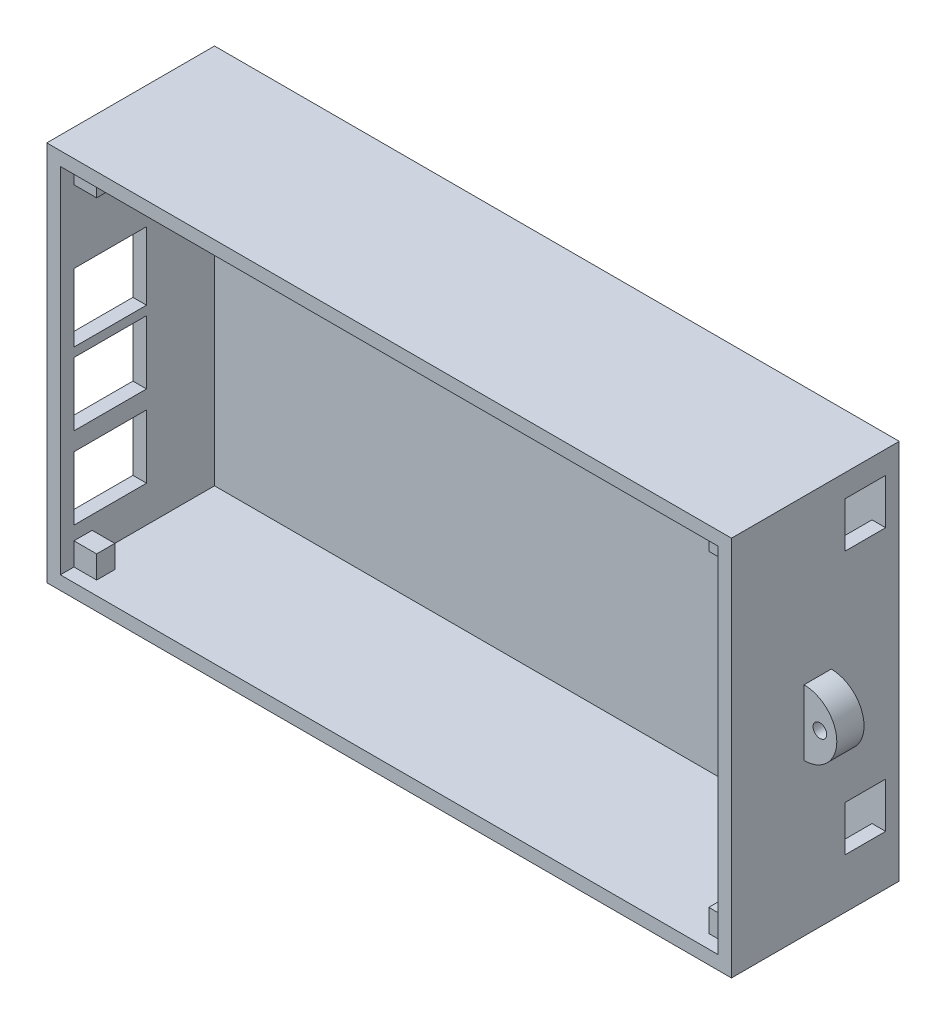
from build123d import *

# Parameters (mm, degrees)
SKETCH1_W                = 151
SKETCH1_H                = 84
BOSS_EXTRUDE1_DEPTH      = 37
SKETCH3_W                = 145
SKETCH3_H                = 78
CUT_EXTRUDE3_DEPTH       = 34
SKETCH8_W                = 19
SKETCH8_H                = 14
CUT_EXTRUDE4_DEPTH       = 3
SKETCH9_W                = 19
SKETCH9_H                = 14
CUT_EXTRUDE5_DEPTH       = 3
SKETCH11_W               = 9
SKETCH11_H               = 10
CUT_EXTRUDE6_DEPTH       = 3
SKETCH12_W               = 9
SKETCH12_H               = 10
CUT_EXTRUDE7_DEPTH       = 3
BOSS_EXTRUDE2_DEPTH      = 3
BOSS_EXTRUDE2_DEPTH_BACK = 3
SKETCH19_R               = 1.5
CUT_EXTRUDE8_DEPTH       = 6
SKETCH20_W               = 3
SKETCH20_H               = 14
BOSS_EXTRUDE3_DEPTH      = 3
SKETCH21_W               = 3
SKETCH21_H               = 14
BOSS_EXTRUDE4_DEPTH      = 3
SKETCH23_W               = 16
SKETCH23_H               = 15
CUT_EXTRUDE9_DEPTH       = 3
SKETCH28_W               = 4
SKETCH28_H               = 5
BOSS_EXTRUDE5_DEPTH      = 5
MIRROR2_COPY_1_SKETCH_W  = 4
MIRROR2_COPY_1_SKETCH_H  = 5
MIRROR2_COPY_1_DEPTH     = 5


with BuildPart() as part:
    # Sketch1 → Boss-Extrude1 (new body)
    with BuildSketch(Plane.XY):
        Rectangle(SKETCH1_W, SKETCH1_H)
    extrude(amount=BOSS_EXTRUDE1_DEPTH)

    # Sketch3 → Cut-Extrude3 (cut)
    with BuildSketch(Plane.XY.offset(37)):
        Rectangle(SKETCH3_W, SKETCH3_H)
    extrude(amount=-CUT_EXTRUDE3_DEPTH, mode=Mode.SUBTRACT)

    # Sketch8 → Cut-Extrude4 (cut)
    with BuildSketch(Plane.ZY.offset(75.5)):
        with Locations((27.5, -24)):
            Rectangle(SKETCH8_W, SKETCH8_H)
    extrude(amount=-CUT_EXTRUDE4_DEPTH, mode=Mode.SUBTRACT)

    # Sketch9 → Cut-Extrude5 (cut)
    with BuildSketch(Plane.ZY.offset(75.5)):
        with Locations((27.5, -6)):
            Rectangle(SKETCH9_W, SKETCH9_H)
    extrude(amount=-CUT_EXTRUDE5_DEPTH, mode=Mode.SUBTRACT)

    # Sketch11 → Cut-Extrude6 (cut)
    with BuildSketch(Plane(origin=(75.5, 0, 0), x_dir=(0, 0, -1), z_dir=(1, 0, 0))):
        with Locations((-7.5, 32)):
            Rectangle(SKETCH11_W, SKETCH11_H)
    extrude(amount=-CUT_EXTRUDE6_DEPTH, mode=Mode.SUBTRACT)

    # Sketch12 → Cut-Extrude7 (cut)
    with BuildSketch(Plane(origin=(75.5, 0, 0), x_dir=(0, 0, -1), z_dir=(1, 0, 0))):
        with Locations((-7.5, -26)):
            Rectangle(SKETCH12_W, SKETCH12_H)
    extrude(amount=-CUT_EXTRUDE7_DEPTH, mode=Mode.SUBTRACT)

    # Sketch16 → Boss-Extrude2 (add, two sides)
    with BuildSketch(Plane.XY.offset(18)) as boss_extrude2_sk:
        with BuildLine():
            Line((75.5, 6), (75.5, -8.461119278))
            ThreePointArc((75.5, -8.461119278), (82.730559639, -1.230559639), (75.5, 6))
        make_face()
    extrude(amount=BOSS_EXTRUDE2_DEPTH)
    extrude(boss_extrude2_sk.sketch, amount=-BOSS_EXTRUDE2_DEPTH_BACK)

    # Sketch19 → Cut-Extrude8 (cut)
    with BuildSketch(Plane.XY.offset(21)):
        with Locations((79, -1)):
            Circle(SKETCH19_R)
    extrude(amount=-CUT_EXTRUDE8_DEPTH, mode=Mode.SUBTRACT)

    # Sketch20 → Boss-Extrude3 (add)
    with BuildSketch(Plane.ZY.offset(75.5)):
        with Locations((35.5, -6)):
            Rectangle(SKETCH20_W, SKETCH20_H)
    extrude(amount=-BOSS_EXTRUDE3_DEPTH)

    # Sketch21 → Boss-Extrude4 (add)
    with BuildSketch(Plane.ZY.offset(75.5)):
        with Locations((35.5, -24)):
            Rectangle(SKETCH21_W, SKETCH21_H)
    extrude(amount=-BOSS_EXTRUDE4_DEPTH)

    # Sketch23 → Cut-Extrude9 (cut)
    with BuildSketch(Plane.ZY.offset(75.5)):
        with Locations((26, 10.5)):
            Rectangle(SKETCH23_W, SKETCH23_H)
    extrude(amount=-CUT_EXTRUDE9_DEPTH, mode=Mode.SUBTRACT)

    # Sketch28 → Boss-Extrude5 (add)
    with BuildSketch(Plane.ZY.offset(-72.5)):
        with Locations((32, -36.5)):
            Rectangle(SKETCH28_W, SKETCH28_H)
    boss_extrude5 = extrude(amount=BOSS_EXTRUDE5_DEPTH)

    # Mirror1: Boss-Extrude5 across plane
    add(boss_extrude5.mirror(Plane.ZX))

    # Mirror2: Boss-Extrude5 across plane
    add(boss_extrude5.mirror(Plane(origin=(0, 0, 0), x_dir=(0, 0, 1), z_dir=(1, 0, 0))))

    # Mirror2 copy 1 sketch → Mirror2 copy 1 (add)
    with BuildSketch(Plane(origin=(-72.5, 0, 0), x_dir=(0, 0, 1), z_dir=(1, 0, 0))):
        with Locations((32, -36.5)):
            Rectangle(MIRROR2_COPY_1_SKETCH_W, MIRROR2_COPY_1_SKETCH_H)
    extrude(amount=MIRROR2_COPY_1_DEPTH)


solid = part.part
